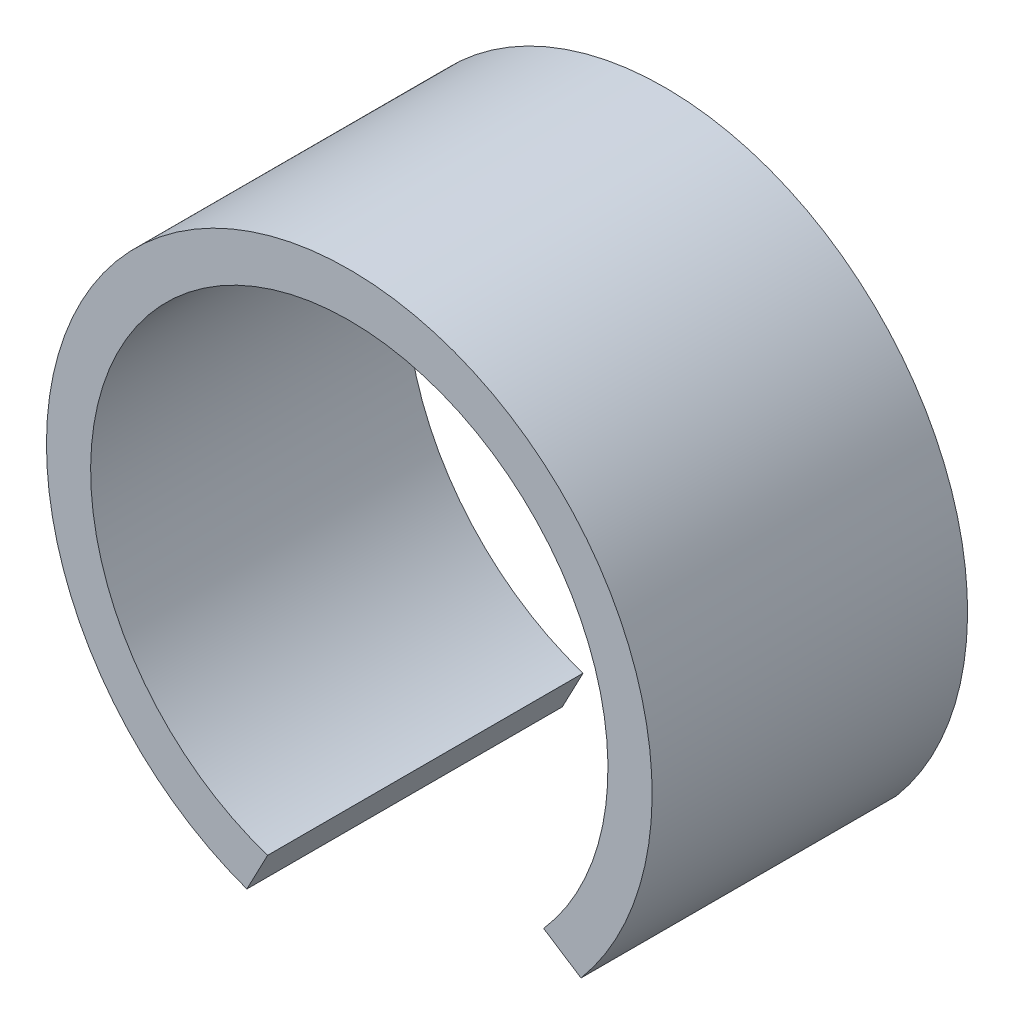
from build123d import *

# Parameters (mm, degrees)
BOSS_EXTRUDE1_DEPTH = 25


with BuildPart() as part:
    # Sketch1 → Boss-Extrude1 (new body)
    with BuildSketch(Plane.XY):
        with BuildLine():
            Line((-8.117441967, -22.585551486), (-6.473192498, -19.451163947))
            ThreePointArc((-6.473192498, -19.451163947), (-11.990612032, 16.627544109), (20.5, 0))
            ThreePointArc((20.5, 0), (19.182709681, -7.230051818), (15.400131776, -13.530925366))
            Line((15.400131776, -13.530925366), (18.363939094, -15.452046497))
            ThreePointArc((18.363939094, -15.452046497), (22.547001334, -8.223912139), (24, 0))
            ThreePointArc((24, 0), (-13.805458935, 19.631844121), (-8.117441967, -22.585551486))
        make_face()
    extrude(amount=BOSS_EXTRUDE1_DEPTH)


solid = part.part
